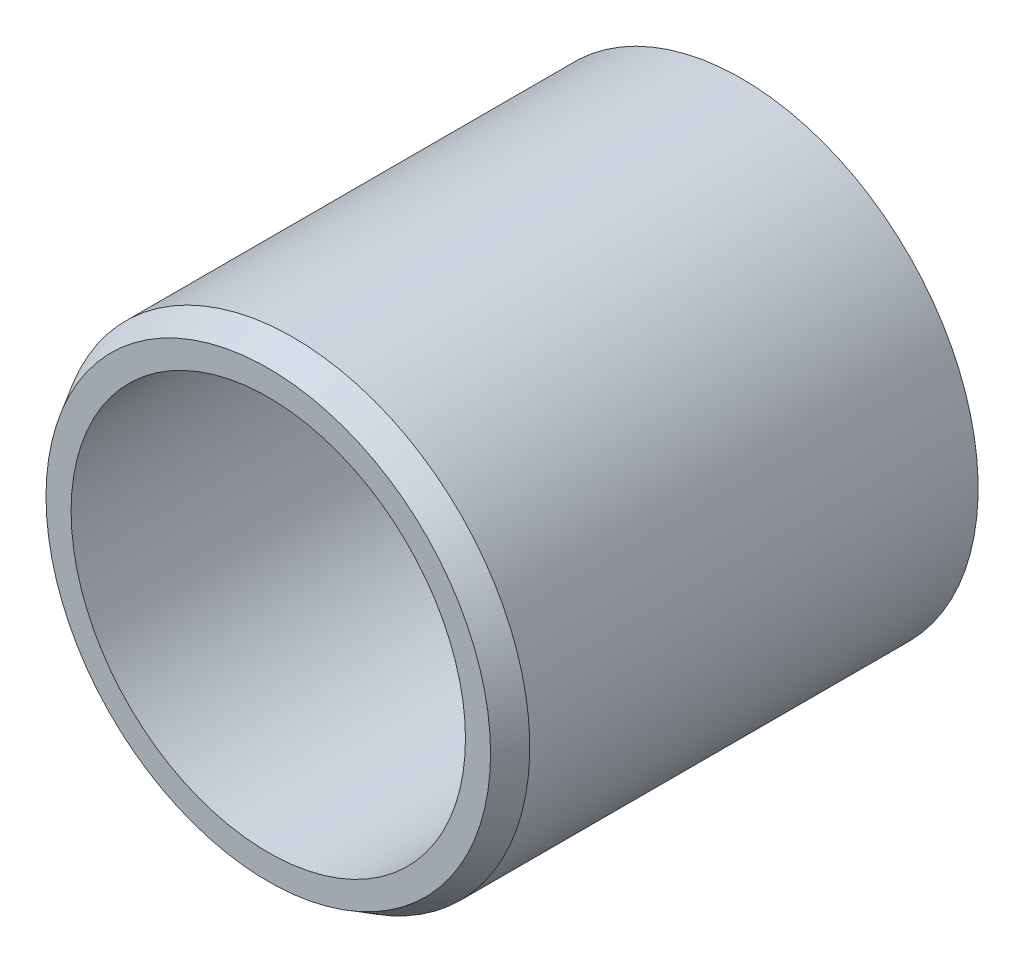
from build123d import *


with BuildPart() as part:
    # Sketch1 → Revolve1 (revolve)
    with BuildSketch(Plane.XZ):
        Polygon((4.473824865, 9.525), (3.96875, 9.525), (3.96875, 0.5), (4.257425135, 0), (4.7625, 0), (4.7625, 9.025), align=None)
    revolve(axis=Axis((0, 0, 9.525), (0, 0, -1)))


solid = part.part
